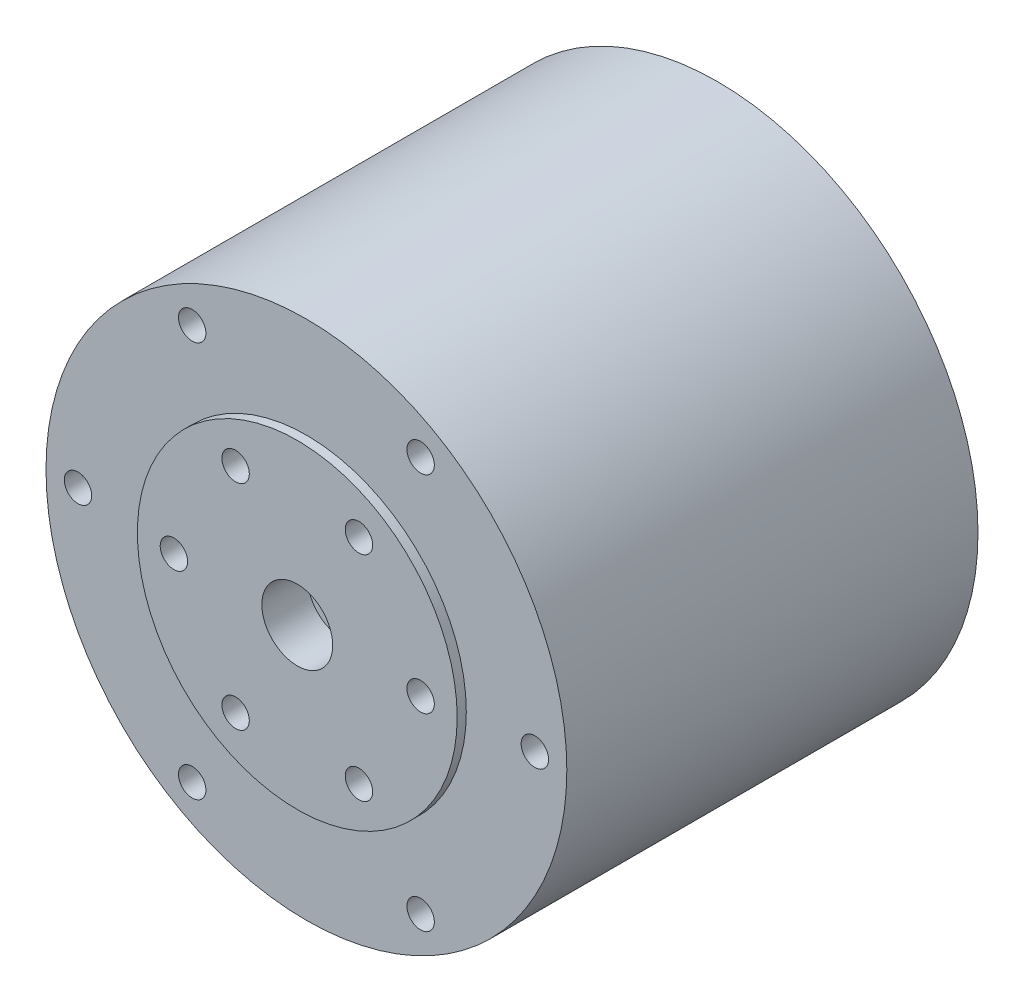
from build123d import *

# Parameters (mm, degrees)
SKETCH_1_R          = 28.5
EXTRUDE_1_DEPTH     = 45
SKETCH_2_R          = 1.5
CUT_EXTRUDE_1_DEPTH = 4
SKETCH_3_R          = 1.5
CUT_EXTRUDE_2_DEPTH = 5
SKETCH_4_R          = 17.5
EXTRUDE_2_DEPTH     = 1
SKETCH_5_R          = 1.5
SKETCH_5_R_2        = 3.876309497
CUT_EXTRUDE_3_DEPTH = 5


with BuildPart() as part:
    # 草图1 → 凸台-拉伸1 (new body)
    with BuildSketch(Plane.XY):
        Circle(SKETCH_1_R)
    extrude(amount=EXTRUDE_1_DEPTH)

    # 草图2 → 切除-拉伸1 (cut)
    with BuildSketch(Plane(origin=(0, 0, 0), x_dir=(-1, 0, 0), z_dir=(0, 0, -1))):
        with Locations((13.435028843, -13.435028843)):
            Circle(SKETCH_2_R)
        with Locations((-13.435028843, -13.435028843)):
            Circle(SKETCH_2_R)
        with Locations((-13.435028843, 13.435028843)):
            Circle(SKETCH_2_R)
        with Locations((13.435028843, 13.435028843)):
            Circle(SKETCH_2_R)
    extrude(amount=-CUT_EXTRUDE_1_DEPTH, mode=Mode.SUBTRACT)

    # 草图3 → 切除-拉伸2 (cut)
    with BuildSketch(Plane.XY.offset(45)):
        with Locations((-12.5, -21.650635095)):
            Circle(SKETCH_3_R)
        with Locations((-12.5, 21.650635095)):
            Circle(SKETCH_3_R)
        with Locations((12.5, 21.650635095)):
            Circle(SKETCH_3_R)
        with Locations((12.5, -21.650635095)):
            Circle(SKETCH_3_R)
        with Locations((-25, 0)):
            Circle(SKETCH_3_R)
        with Locations((25, 0)):
            Circle(SKETCH_3_R)
    extrude(amount=-CUT_EXTRUDE_2_DEPTH, mode=Mode.SUBTRACT)

    # 草图4 → 凸台-拉伸2 (add)
    with BuildSketch(Plane.XY.offset(45)):
        Circle(SKETCH_4_R)
    extrude(amount=EXTRUDE_2_DEPTH)

    # 草图5 → 切除-拉伸3 (cut)
    with BuildSketch(Plane.XY.offset(46)):
        with Locations((13.5, 0)):
            Circle(SKETCH_5_R)
        with Locations((-13.5, 0)):
            Circle(SKETCH_5_R)
        with Locations((6.75, 11.691342951)):
            Circle(SKETCH_5_R)
        with Locations((-6.75, 11.691342951)):
            Circle(SKETCH_5_R)
        with Locations((-6.75, -11.691342951)):
            Circle(SKETCH_5_R)
        with Locations((6.75, -11.691342951)):
            Circle(SKETCH_5_R)
        Circle(SKETCH_5_R_2)
    extrude(amount=-CUT_EXTRUDE_3_DEPTH, mode=Mode.SUBTRACT)


solid = part.part
